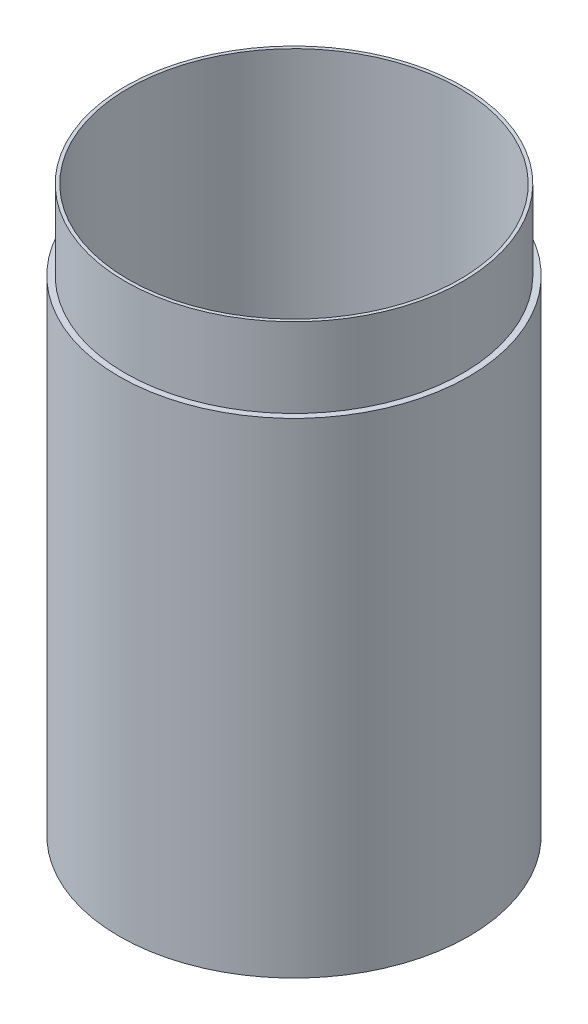
from build123d import *

# Parameters (mm, degrees)
SKETCH1_R           = 44
SKETCH1_R_2         = 40
BOSS_EXTRUDE1_DEPTH = 22
SKETCH2_R           = 44
SKETCH2_R_2         = 41.68814
BOSS_EXTRUDE2_DEPTH = 100
SKETCH3_R           = 42.5
SKETCH3_R_2         = 41.68814
BOSS_EXTRUDE3_DEPTH = 20


with BuildPart() as part:
    # Sketch1 → Boss-Extrude1 (new body)
    with BuildSketch(Plane(origin=(0, 0, 0), x_dir=(1, 0, 0), z_dir=(0, 1, 0))):
        Circle(SKETCH1_R)
        Circle(SKETCH1_R_2, mode=Mode.SUBTRACT)
    extrude(amount=BOSS_EXTRUDE1_DEPTH)

    # Sketch2 → Boss-Extrude2 (add)
    with BuildSketch(Plane(origin=(0, 22, 0), x_dir=(1, 0, 0), z_dir=(0, 1, 0))):
        Circle(SKETCH2_R)
        Circle(SKETCH2_R_2, mode=Mode.SUBTRACT)
    extrude(amount=BOSS_EXTRUDE2_DEPTH)

    # Sketch3 → Boss-Extrude3 (add)
    with BuildSketch(Plane(origin=(0, 122, 0), x_dir=(1, 0, 0), z_dir=(0, 1, 0))):
        Circle(SKETCH3_R)
        Circle(SKETCH3_R_2, mode=Mode.SUBTRACT)
    extrude(amount=BOSS_EXTRUDE3_DEPTH)


solid = part.part
